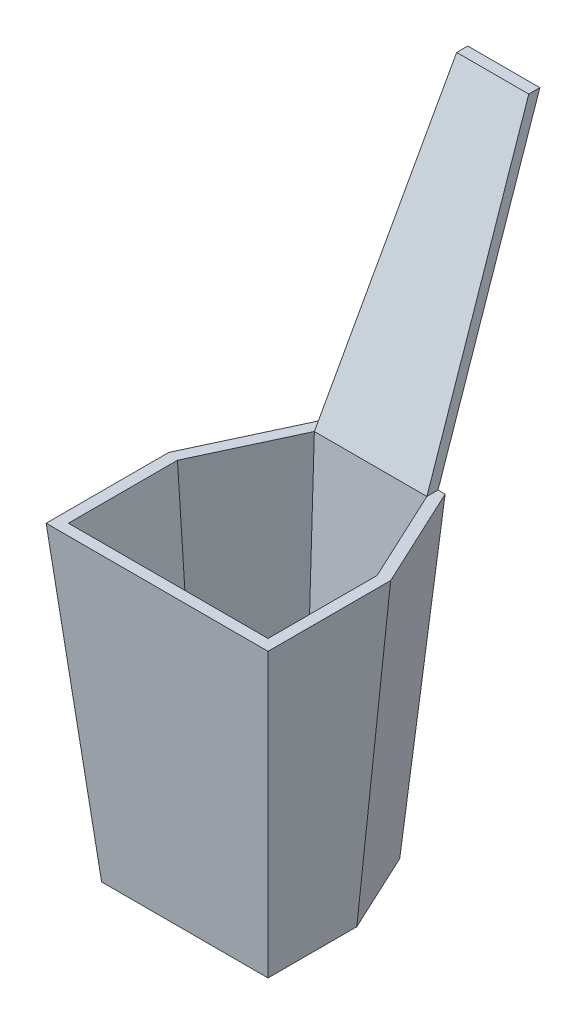
from build123d import *

# Parameters (mm, degrees)
SHELL1_T  = -2.54
SKETCH8_W = 25.766394978
SKETCH8_H = 2.550104265
SKETCH6_W = 16.51
SKETCH6_H = 2.54


with BuildPart() as part:
    # Sketch3 → Loft2 section 0
    with BuildSketch(Plane(origin=(0, 71.12, 0), x_dir=(1, 0, 0), z_dir=(0, 1, 0))):
        Polygon((-14.507793078, 34.926174233), (14.507793078, 34.926174233), (25.4, 11.567761108), (25.4, -16.51), (-25.4, -16.51), (-25.4, 11.567761108), align=None)
    # Sketch1 → Loft2 section 1
    with BuildSketch(Plane(origin=(0, 0, 0), x_dir=(1, 0, 0), z_dir=(0, 1, 0))):
        Polygon((-10.462396921, 28.576174233), (10.462396921, 28.576174233), (19.05, 10.16), (19.05, -10.16), (-19.05, -10.16), (-19.05, 10.16), align=None)
    loft()

    # Shell1
    shell1_openings = [part.faces().sort_by_distance(p)[0] for p in [
        (0, 71.12, -9.994645113),
    ]]
    offset(amount=SHELL1_T, openings=shell1_openings, kind=Kind.INTERSECTION)

    # Sketch8 → Loft3 section 0
    with BuildSketch(Plane(origin=(0, 71.12, 0), x_dir=(1, 0, 0), z_dir=(0, 1, 0))):
        with Locations((0, 33.651122101)):
            Rectangle(SKETCH8_W, SKETCH8_H)
    # Sketch6 → Loft3 section 1
    with BuildSketch(Plane(origin=(0, 134.62, 0), x_dir=(1, 0, 0), z_dir=(0, 1, 0))):
        with Locations((0, 61.596174233)):
            Rectangle(SKETCH6_W, SKETCH6_H)
    loft()


solid = part.part
